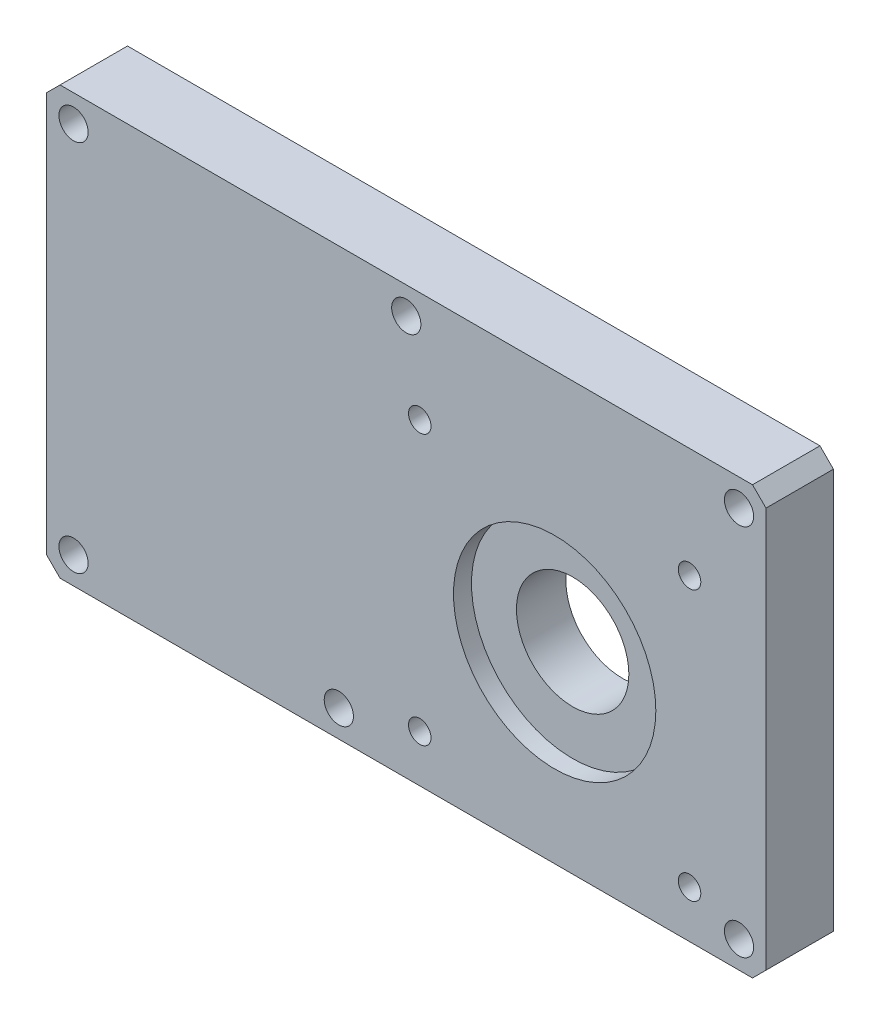
from build123d import *

# Parameters (mm, degrees)
SKETCH_1_W             = 160
SKETCH_1_H             = 95
EXTRUDE_1_DEPTH        = 15
CHAMFER_1_SIZE         = 3
SKETCH_2_R             = 12.5
CUT_EXTRUDE_1_DEPTH    = 16
HOLE_WIZARD_M6_1_D     = 5
HOLE_WIZARD_M6_1_DEPTH = 20
HOLE_WIZARD_M6_1_TIP   = 1.502151548
SKETCH_6_R             = 5.25
CUT_EXTRUDE_2_DEPTH    = 7
SKETCH_7_R             = 3.25
CUT_EXTRUDE_3_DEPTH    = 9
SKETCH_8_R             = 22.5
CUT_EXTRUDE_4_DEPTH    = 4


with BuildPart() as part:
    # 草图1 → 凸台-拉伸1 (new body)
    with BuildSketch(Plane.XY):
        with Locations((80, -47.5)):
            Rectangle(SKETCH_1_W, SKETCH_1_H)
    extrude(amount=EXTRUDE_1_DEPTH)

    # 倒角1
    chamfer_1_edges = [part.edges().sort_by_distance(p)[0] for p in [
        (0, 0, 7.5),
        (160, 0, 7.5),
        (160, -95, 7.5),
        (0, -95, 7.5),
    ]]
    chamfer(chamfer_1_edges, length=CHAMFER_1_SIZE)

    # 草图2 → 切除-拉伸1 (cut, through all)
    with BuildSketch(Plane(origin=(0, 0, 0), x_dir=(-1, 0, 0), z_dir=(0, 0, -1))):
        with Locations((-113, -54.25)):
            Circle(SKETCH_2_R)
    extrude(amount=-CUT_EXTRUDE_1_DEPTH, mode=Mode.SUBTRACT)

    # M6 螺纹孔1
    with Locations(Plane(origin=(0, 0, 0), x_dir=(-1, 0, 0), z_dir=(0, 0, -1))):
        with Locations((-143, -24.5), (-83, -24.5), (-83, -84.5), (-143, -84.5)):
            Hole(HOLE_WIZARD_M6_1_D / 2, depth=HOLE_WIZARD_M6_1_DEPTH)
            with Locations((0, 0, -(HOLE_WIZARD_M6_1_DEPTH + HOLE_WIZARD_M6_1_TIP / 2))):  # 118° drill point
                Cone(0, HOLE_WIZARD_M6_1_D / 2, HOLE_WIZARD_M6_1_TIP, mode=Mode.SUBTRACT)

    # 草图6 → 切除-拉伸2 (cut)
    with BuildSketch(Plane(origin=(0, 0, 0), x_dir=(-1, 0, 0), z_dir=(0, 0, -1))):
        with Locations((-154, -6)):
            Circle(SKETCH_6_R)
        with Locations((-80, -6)):
            Circle(SKETCH_6_R)
        with Locations((-6, -6)):
            Circle(SKETCH_6_R)
        with Locations((-6, -89)):
            Circle(SKETCH_6_R)
        with Locations((-154, -89)):
            Circle(SKETCH_6_R)
        with Locations((-65, -89)):
            Circle(SKETCH_6_R)
    extrude(amount=-CUT_EXTRUDE_2_DEPTH, mode=Mode.SUBTRACT)

    # 草图7 → 切除-拉伸3 (cut, through all)
    with BuildSketch(Plane(origin=(0, 0, 7), x_dir=(-1, 0, 0), z_dir=(0, 0, -1))):
        with Locations((-154, -6)):
            Circle(SKETCH_7_R)
        with Locations((-80, -6)):
            Circle(SKETCH_7_R)
        with Locations((-6, -6)):
            Circle(SKETCH_7_R)
        with Locations((-6, -89)):
            Circle(SKETCH_7_R)
        with Locations((-154, -89)):
            Circle(SKETCH_7_R)
        with Locations((-65, -89)):
            Circle(SKETCH_7_R)
    extrude(amount=-CUT_EXTRUDE_3_DEPTH, mode=Mode.SUBTRACT)

    # 草图8 → 切除-拉伸4 (cut)
    with BuildSketch(Plane.XY.offset(15)):
        with Locations((113, -54.25)):
            Circle(SKETCH_8_R)
    extrude(amount=-CUT_EXTRUDE_4_DEPTH, mode=Mode.SUBTRACT)


solid = part.part
